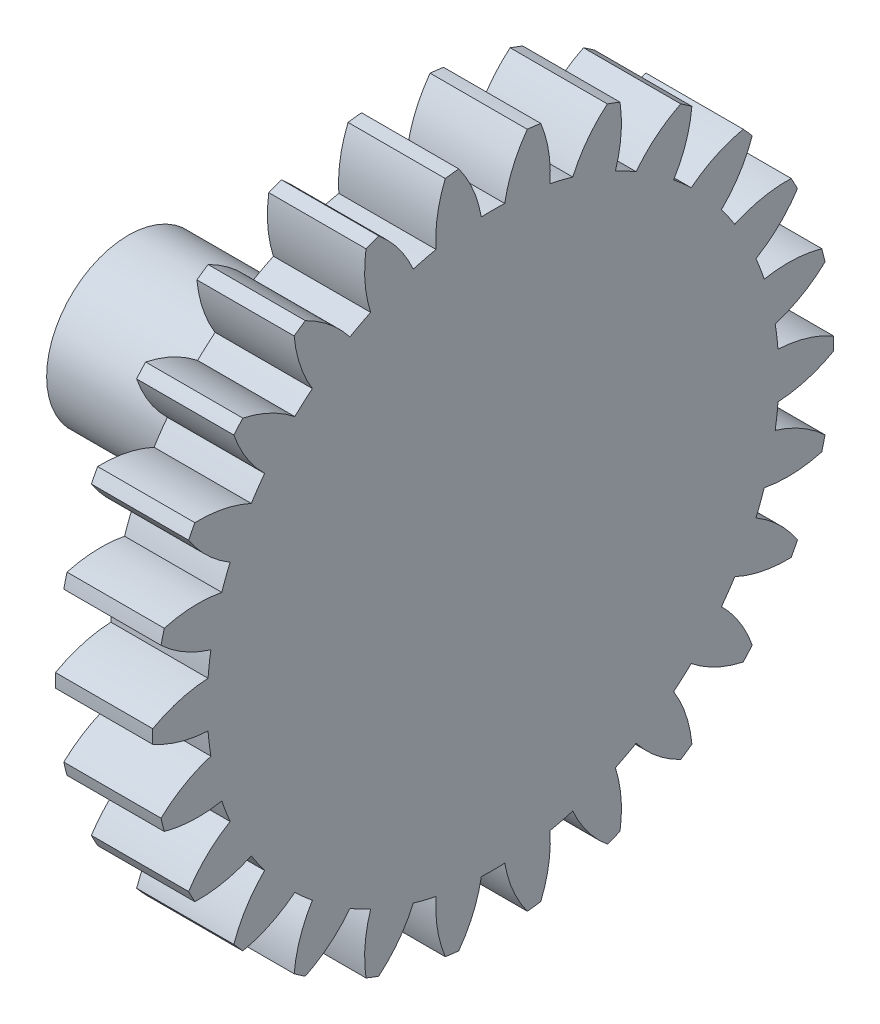
from build123d import *

# Parameters (mm, degrees)
BASPROSKE_W         = 5.08
BASPROSKE_H         = 17.78
TOOTHCUT_DEPTH      = 26.652742543
TEETHCUTS_COUNT     = 26
TEETHCUTS_ANGLE     = 346.153846154
BORSKE_R            = 0.99949
BORE_DEPTH          = 50.8000508
SKETCH1_R           = 0.99949
BOSS_EXTRUDE1_DEPTH = 5.08
SKETCH2_R           = 4.269994
BOSS_EXTRUDE2_DEPTH = 13.97
SKETCH3_R           = 2.649982
CUT_EXTRUDE1_DEPTH  = 3.81


with BuildPart() as part:
    # BasProSke → Base-Revolve (revolve)
    with BuildSketch(Plane(origin=(0, 0, 0), x_dir=(1, 0, 0), z_dir=(0, 1, 0)), mode=Mode.PRIVATE) as base_revolve_sk:
        with Locations((2.54, 8.89)):
            Rectangle(BASPROSKE_W, BASPROSKE_H)
    revolve(base_revolve_sk.sketch.rotate(Axis((-10, 0, 0), (1, 0, 0)), 180), axis=Axis((-10, 0, 0), (1, 0, 0)))

    # TooCutSke → ToothCut (cut, through all)
    with BuildSketch(Plane(origin=(0, 0, 0), x_dir=(0, 0, -1), z_dir=(1, 0, 0))):
        with BuildLine():
            ThreePointArc((0.612177536, 14.922648482), (0, 14.9352), (-0.612177536, 14.922648482))
            ThreePointArc((-0.612177536, 14.922648482), (-1.047858816, 16.387671439), (-1.808659463, 17.713300655))
            ThreePointArc((-1.808659463, 17.713300655), (0, 17.8054), (1.808659463, 17.713300655))
            ThreePointArc((1.808659463, 17.713300655), (1.047858816, 16.387671439), (0.612177536, 14.922648482))
        make_face()
    toothcut = extrude(amount=TOOTHCUT_DEPTH, mode=Mode.SUBTRACT)

    # TeethCuts: ToothCut ×26 about axis
    teethcuts_axis = Axis((-10, 0, 0), (1, 0, 0))
    for i in range(1, TEETHCUTS_COUNT):
        add(toothcut.rotate(teethcuts_axis, i * TEETHCUTS_ANGLE / (TEETHCUTS_COUNT - 1)), mode=Mode.SUBTRACT)

    # BorSke → Bore (cut, symmetric)
    with BuildSketch(Plane(origin=(0, 0, 0), x_dir=(0, 0, -1), z_dir=(1, 0, 0))):
        with Locations(Location((0, 0, 0), (0, 0, 180))):
            Circle(BORSKE_R)
    extrude(amount=BORE_DEPTH, both=True, mode=Mode.SUBTRACT)

    # Sketch1 → Boss-Extrude1 (add)
    with BuildSketch(Plane(origin=(5.08, 0, 0), x_dir=(0, 0, -1), z_dir=(1, 0, 0))):
        Circle(SKETCH1_R)
    extrude(amount=-BOSS_EXTRUDE1_DEPTH)

    # Sketch2 → Boss-Extrude2 (add)
    with BuildSketch(Plane.ZY):
        with Locations(Location((0, 0, 0), (0, 0, 180))):
            Circle(SKETCH2_R)
    extrude(amount=BOSS_EXTRUDE2_DEPTH)

    # Sketch3 → Cut-Extrude1 (cut)
    with BuildSketch(Plane.ZY.offset(13.97)):
        Circle(SKETCH3_R)
    extrude(amount=-CUT_EXTRUDE1_DEPTH, mode=Mode.SUBTRACT)


solid = part.part
